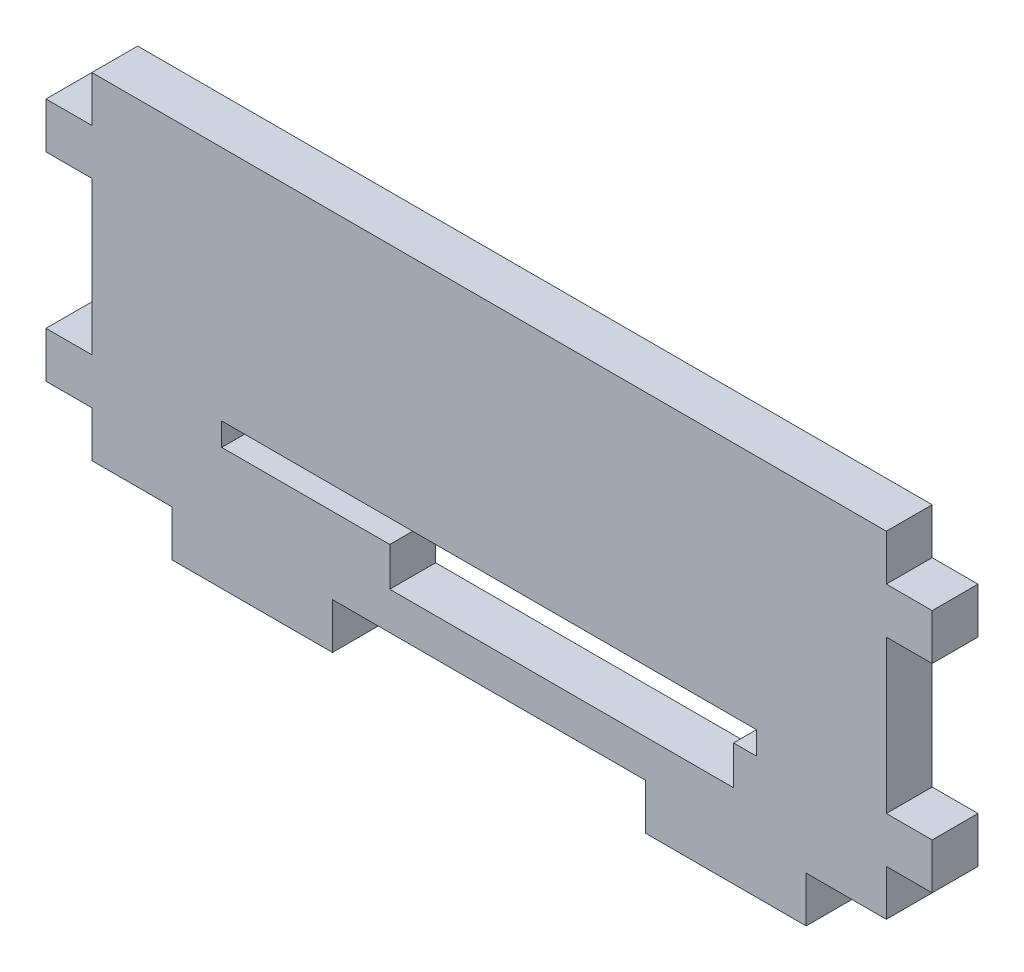
from build123d import *

# Parameters (mm, degrees)
SKETCH1_W           = 52
SKETCH1_H           = 22
BOSS_EXTRUDE1_DEPTH = 3
SKETCH2_W           = 3
SKETCH2_H           = 3
BOSS_EXTRUDE2_DEPTH = 3
SKETCH3_W           = 3
SKETCH3_H           = 3
BOSS_EXTRUDE3_DEPTH = 3
SKETCH4_W           = 10.5
SKETCH4_H           = 3
BOSS_EXTRUDE4_DEPTH = 3
SKETCH5_W           = 35
SKETCH5_H           = 1.5
CUT_EXTRUDE1_DEPTH  = 3
SKETCH6_W           = 22.5
SKETCH6_H           = 2.539151914
CUT_EXTRUDE2_DEPTH  = 3


with BuildPart() as part:
    # Sketch1 → Boss-Extrude1 (new body)
    with BuildSketch(Plane.XY):
        Rectangle(SKETCH1_W, SKETCH1_H)
    extrude(amount=BOSS_EXTRUDE1_DEPTH)

    # Sketch2 → Boss-Extrude2 (add)
    with BuildSketch(Plane.ZY.offset(26)):
        with Locations((1.5, 6.5)):
            Rectangle(SKETCH2_W, SKETCH2_H)
        with Locations((1.5, -6.5)):
            Rectangle(SKETCH2_W, SKETCH2_H)
    extrude(amount=BOSS_EXTRUDE2_DEPTH)

    # Sketch3 → Boss-Extrude3 (add)
    with BuildSketch(Plane(origin=(26, 0, 0), x_dir=(0, 0, -1), z_dir=(1, 0, 0))):
        with Locations((-1.5, 6.5)):
            Rectangle(SKETCH3_W, SKETCH3_H)
        with Locations((-1.5, -6.5)):
            Rectangle(SKETCH3_W, SKETCH3_H)
    extrude(amount=BOSS_EXTRUDE3_DEPTH)

    # Sketch4 → Boss-Extrude4 (add)
    with BuildSketch(Plane.XZ.offset(11)):
        with Locations((-15.5, 1.5)):
            Rectangle(SKETCH4_W, SKETCH4_H)
        with Locations((15.5, 1.5)):
            Rectangle(SKETCH4_W, SKETCH4_H)
    extrude(amount=BOSS_EXTRUDE4_DEPTH)

    # Sketch5 → Cut-Extrude1 (cut)
    with BuildSketch(Plane.XY.offset(3)):
        with Locations((0, -5.25)):
            Rectangle(SKETCH5_W, SKETCH5_H)
    extrude(amount=-CUT_EXTRUDE1_DEPTH, mode=Mode.SUBTRACT)

    # Sketch6 → Cut-Extrude2 (cut)
    with BuildSketch(Plane.XY.offset(3)):
        with Locations((4.75, -7.269575957)):
            Rectangle(SKETCH6_W, SKETCH6_H)
    extrude(amount=-CUT_EXTRUDE2_DEPTH, mode=Mode.SUBTRACT)


solid = part.part
